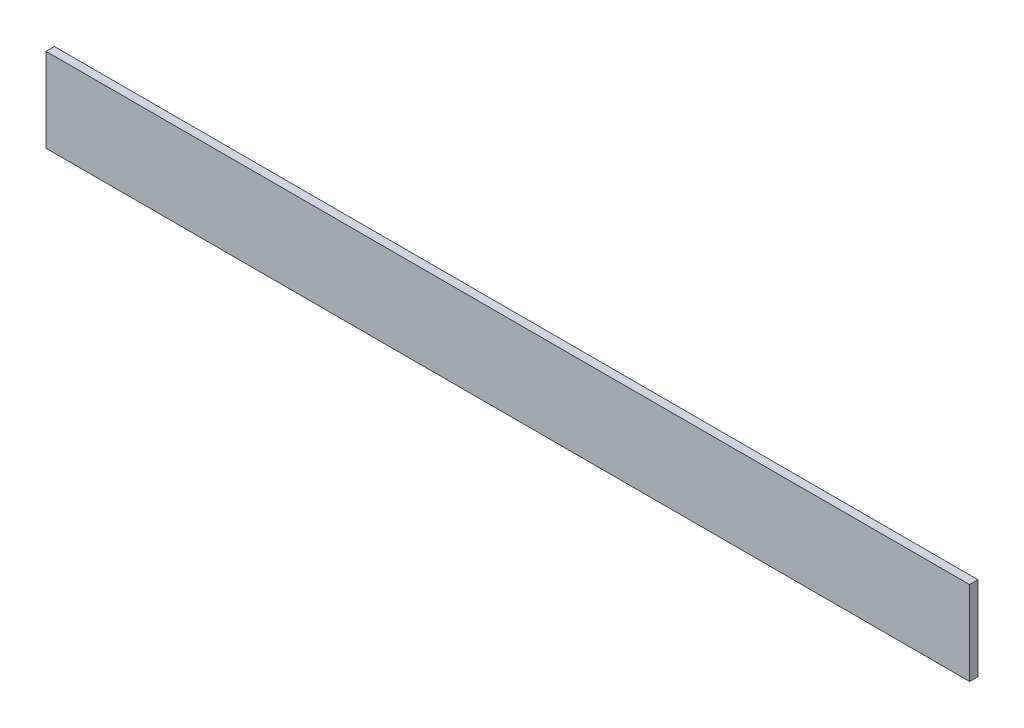
from build123d import *

# Parameters (mm, degrees)
SKETCH1_W           = 550
SKETCH1_H           = 50
BOSS_EXTRUDE1_DEPTH = 5


with BuildPart() as part:
    # Sketch1 → Boss-Extrude1 (new body)
    with BuildSketch(Plane.XY):
        Rectangle(SKETCH1_W, SKETCH1_H)
    extrude(amount=BOSS_EXTRUDE1_DEPTH)


solid = part.part
